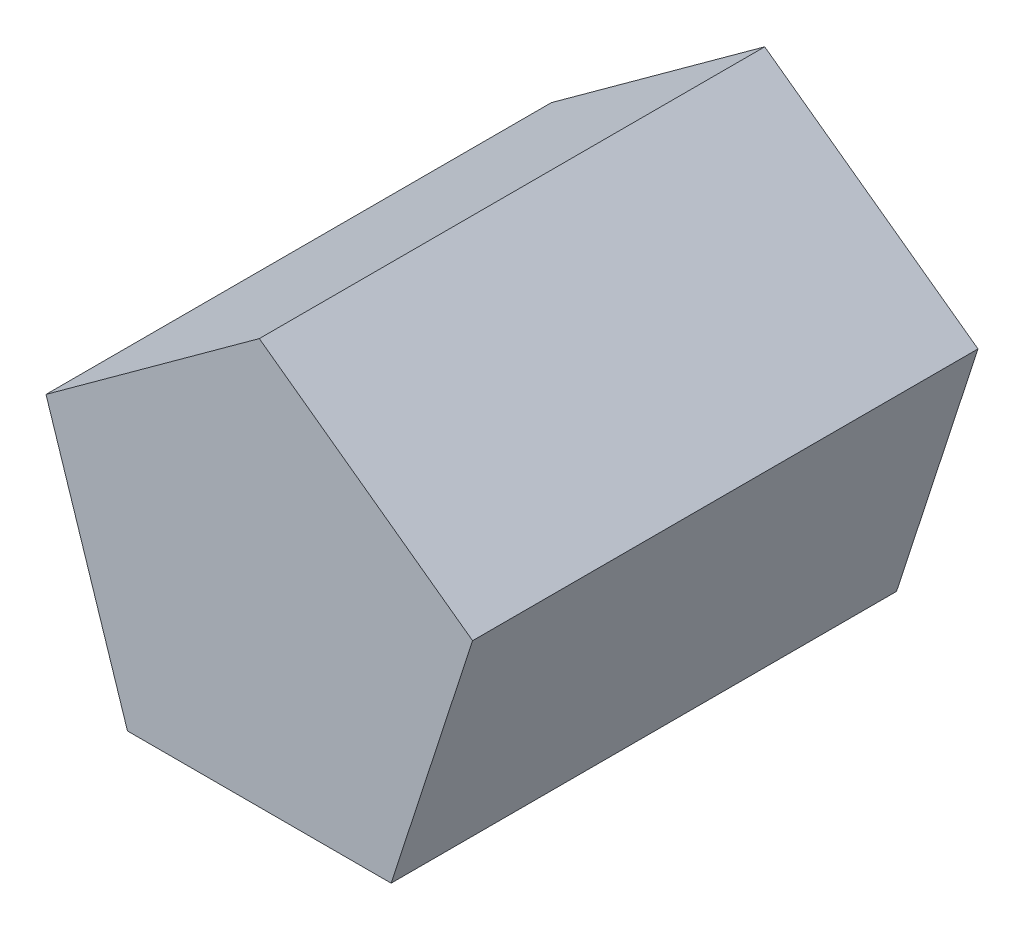
from build123d import *

# Parameters (mm, degrees)
ESTRUSIONE_ESTRUSIONE1_DEPTH = 160


with BuildPart() as part:
    # Schizzo1 → Estrusione-Estrusione1 (new body)
    with BuildSketch(Plane.XY):
        Polygon((41.732752913, -57.440206601), (67.525012657, 21.940206601), (0, 71), (-67.525012657, 21.940206601), (-41.732752913, -57.440206601), align=None)
    extrude(amount=ESTRUSIONE_ESTRUSIONE1_DEPTH)


solid = part.part
